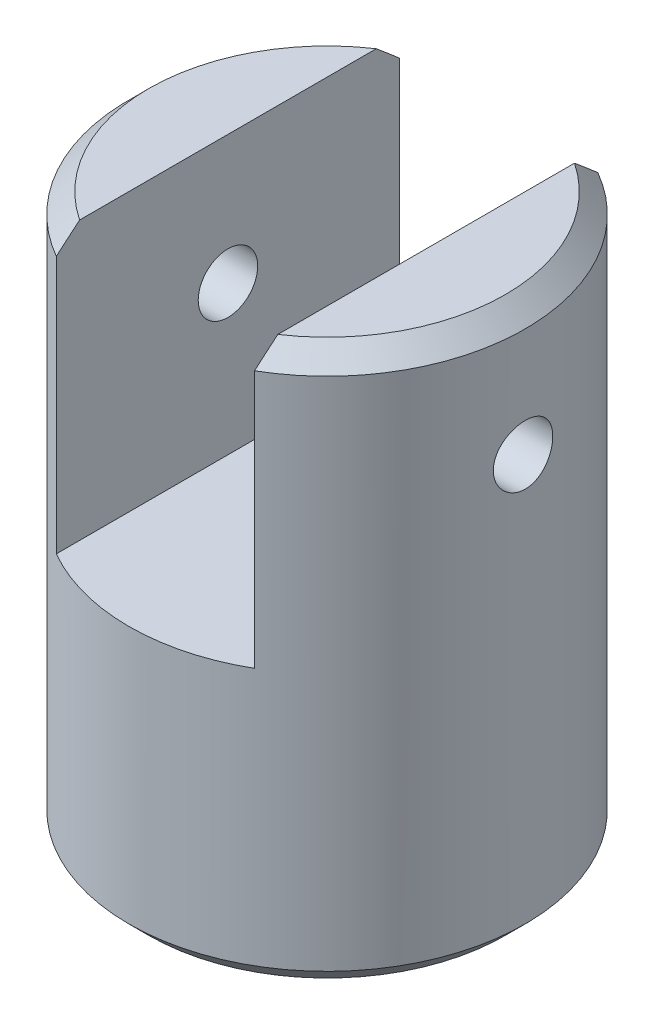
from build123d import *

# Parameters (mm, degrees)
SKETCH1_R                      = 5
BOSS_EXTRUDE1_DEPTH            = 14
CHAMFER1_SIZE                  = 0.5
CUT_EXTRUDE1_REACH             = 16
SKETCH2_R                      = 0.75
SKETCH3_W                      = 5
SKETCH3_H                      = 10
CUT_EXTRUDE2_DEPTH             = 7
CUT_EXTRUDE3_REACH             = 7
SKETCH4_R                      = 0.75
CUT_EXTRUDE3_DIRECTION_2_REACH = 7


with BuildPart() as part:
    # Sketch1 → Boss-Extrude1 (new body)
    with BuildSketch(Plane(origin=(0, 0, 0), x_dir=(1, 0, 0), z_dir=(0, 1, 0))):
        Circle(SKETCH1_R)
    extrude(amount=BOSS_EXTRUDE1_DEPTH)

    # Chamfer1
    chamfer1_edges = [part.edges().sort_by_distance(p)[0] for p in [
        (-5, 0, 0),
        (-5, 14, 0),
    ]]
    chamfer(chamfer1_edges, length=CHAMFER1_SIZE)

    # Sketch2 → Cut-Extrude1 (cut, up to next)
    with BuildSketch(Plane.XZ, mode=Mode.PRIVATE) as cut_extrude1_sk1:
        Circle(SKETCH2_R)
    cut_extrude1_tool1 = extrude(cut_extrude1_sk1.sketch, amount=-CUT_EXTRUDE1_REACH, mode=Mode.PRIVATE) & part.part
    add(cut_extrude1_tool1.solids().sort_by_distance((0, 0, 0))[0], mode=Mode.SUBTRACT)

    # Sketch3 → Cut-Extrude2 (cut)
    with BuildSketch(Plane(origin=(0, 14, 0), x_dir=(1, 0, 0), z_dir=(0, 1, 0))):
        Rectangle(SKETCH3_W, SKETCH3_H)
    extrude(amount=-CUT_EXTRUDE2_DEPTH, mode=Mode.SUBTRACT)

    # Sketch4 → Cut-Extrude3 (cut, up to next)
    with BuildSketch(Plane(origin=(0, 0, 0), x_dir=(0, 0, -1), z_dir=(1, 0, 0)), mode=Mode.PRIVATE) as cut_extrude3_sk1:
        with Locations((0, 10.75)):
            Circle(SKETCH4_R)
    cut_extrude3_tool1 = extrude(cut_extrude3_sk1.sketch, amount=-CUT_EXTRUDE3_REACH, mode=Mode.PRIVATE) & part.part
    add(cut_extrude3_tool1.solids().sort_by_distance((0, 10.75, 0))[0], mode=Mode.SUBTRACT)

    # Sketch4 → Cut-Extrude3 direction 2 (cut, up to next)
    with BuildSketch(Plane(origin=(0, 0, 0), x_dir=(0, 0, -1), z_dir=(1, 0, 0)), mode=Mode.PRIVATE) as cut_extrude3_direction_2_sk1:
        with Locations((0, 10.75)):
            Circle(SKETCH4_R)
    cut_extrude3_direction_2_tool1 = extrude(cut_extrude3_direction_2_sk1.sketch, amount=CUT_EXTRUDE3_DIRECTION_2_REACH, mode=Mode.PRIVATE) & part.part
    add(cut_extrude3_direction_2_tool1.solids().sort_by_distance((0, 10.75, 0))[0], mode=Mode.SUBTRACT)


solid = part.part
